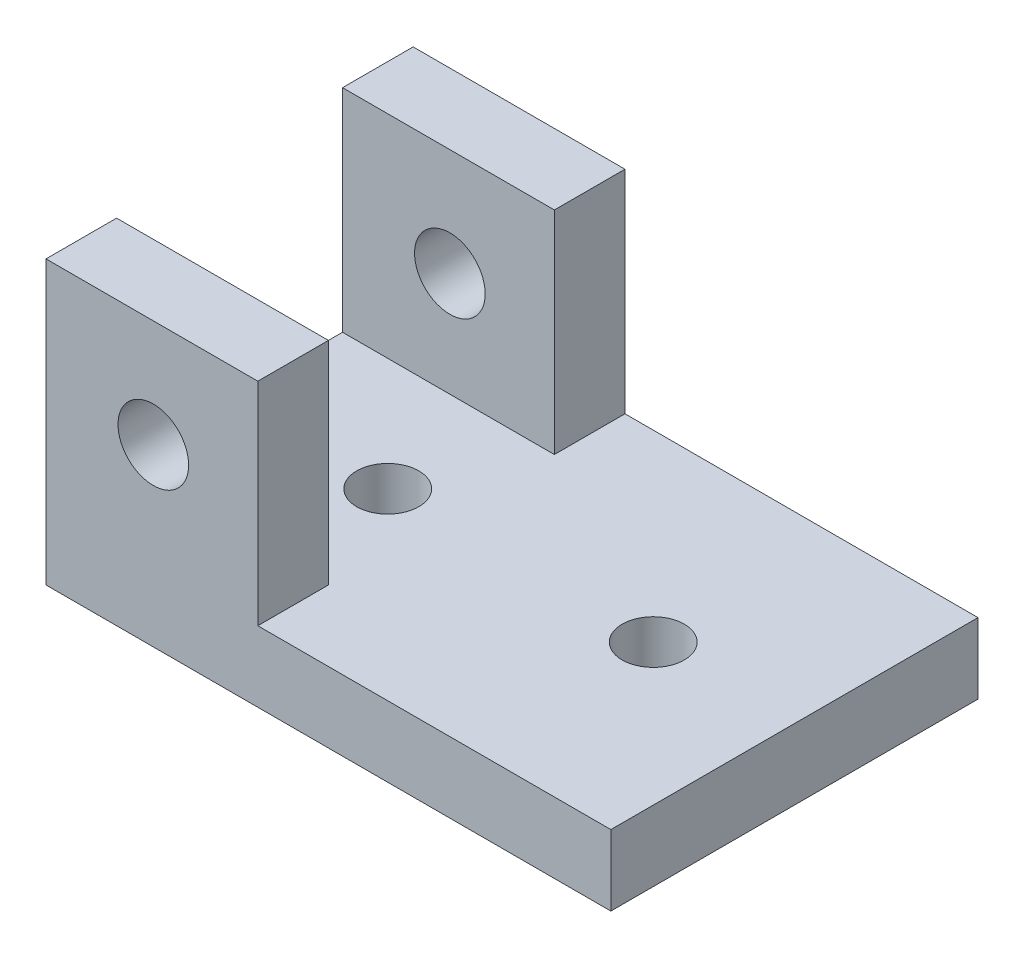
from build123d import *

# Parameters (mm, degrees)
SKETCH3_W           = 50.8
SKETCH3_H           = 33.02
BOSS_EXTRUDE2_DEPTH = 6.35
SKETCH4_R           = 2.794
CUT_EXTRUDE1_DEPTH  = 7.35
SKETCH5_W           = 19.05
SKETCH5_H           = 6.35
BOSS_EXTRUDE3_DEPTH = 19.05
SKETCH7_R           = 3.175
CUT_EXTRUDE2_DEPTH  = 34.29


with BuildPart() as part:
    # Sketch3 → Boss-Extrude2 (new body)
    with BuildSketch(Plane(origin=(0, 0, 0), x_dir=(1, 0, 0), z_dir=(0, 1, 0))):
        with Locations((25.4, 16.51)):
            Rectangle(SKETCH3_W, SKETCH3_H)
    extrude(amount=BOSS_EXTRUDE2_DEPTH)

    # Sketch4 → Cut-Extrude1 (cut, through all)
    with BuildSketch(Plane(origin=(0, 6.35, 0), x_dir=(1, 0, 0), z_dir=(0, 1, 0))):
        with Locations((14.224, 16.51)):
            Circle(SKETCH4_R)
        with Locations((38.1, 16.51)):
            Circle(SKETCH4_R)
    extrude(amount=-CUT_EXTRUDE1_DEPTH, mode=Mode.SUBTRACT)

    # Sketch5 → Boss-Extrude3 (add)
    with BuildSketch(Plane(origin=(0, 6.35, 0), x_dir=(1, 0, 0), z_dir=(0, 1, 0))):
        with Locations((9.525, 3.175)):
            Rectangle(SKETCH5_W, SKETCH5_H)
    boss_extrude3 = extrude(amount=BOSS_EXTRUDE3_DEPTH)

    # Mirror1: Boss-Extrude3 across plane
    add(boss_extrude3.mirror(Plane.XY.offset(-16.51)))

    # Sketch7 → Cut-Extrude2 (cut)
    with BuildSketch(Plane.XY):
        with Locations((9.652, 15.748)):
            Circle(SKETCH7_R)
    extrude(amount=-CUT_EXTRUDE2_DEPTH, mode=Mode.SUBTRACT)


solid = part.part
